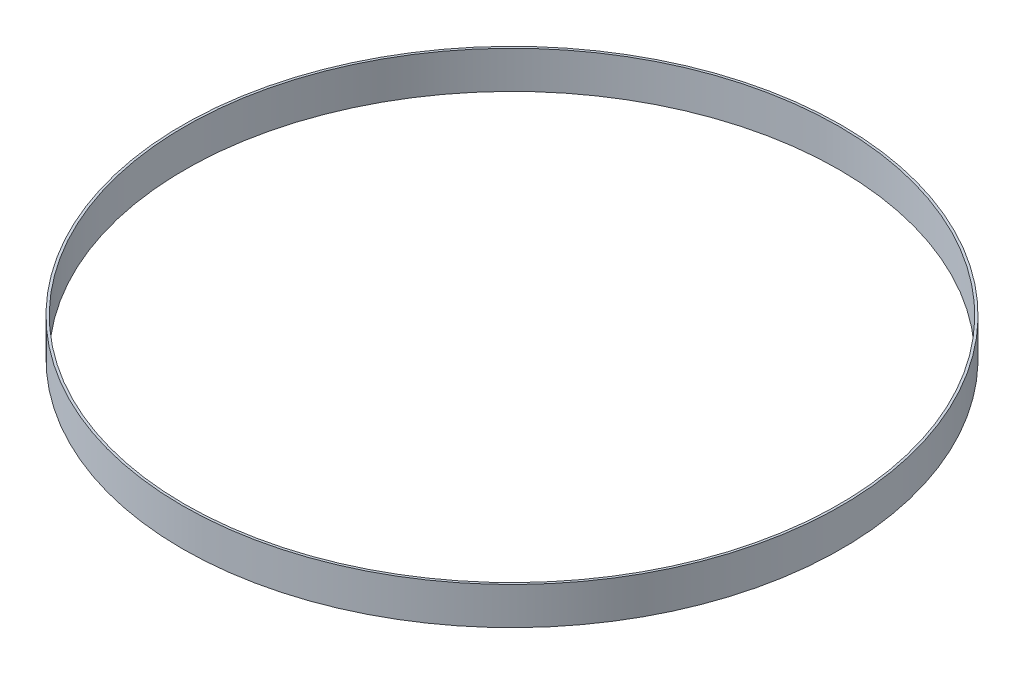
from build123d import *

# Parameters (mm, degrees)
SKETCH2_R           = 70.5
SKETCH2_R_2         = 70
BOSS_EXTRUDE1_DEPTH = 8


with BuildPart() as part:
    # Sketch2 → Boss-Extrude1 (new body)
    with BuildSketch(Plane(origin=(0, 0, 0), x_dir=(1, 0, 0), z_dir=(0, 1, 0))):
        Circle(SKETCH2_R)
        Circle(SKETCH2_R_2, mode=Mode.SUBTRACT)
    extrude(amount=BOSS_EXTRUDE1_DEPTH)


solid = part.part
